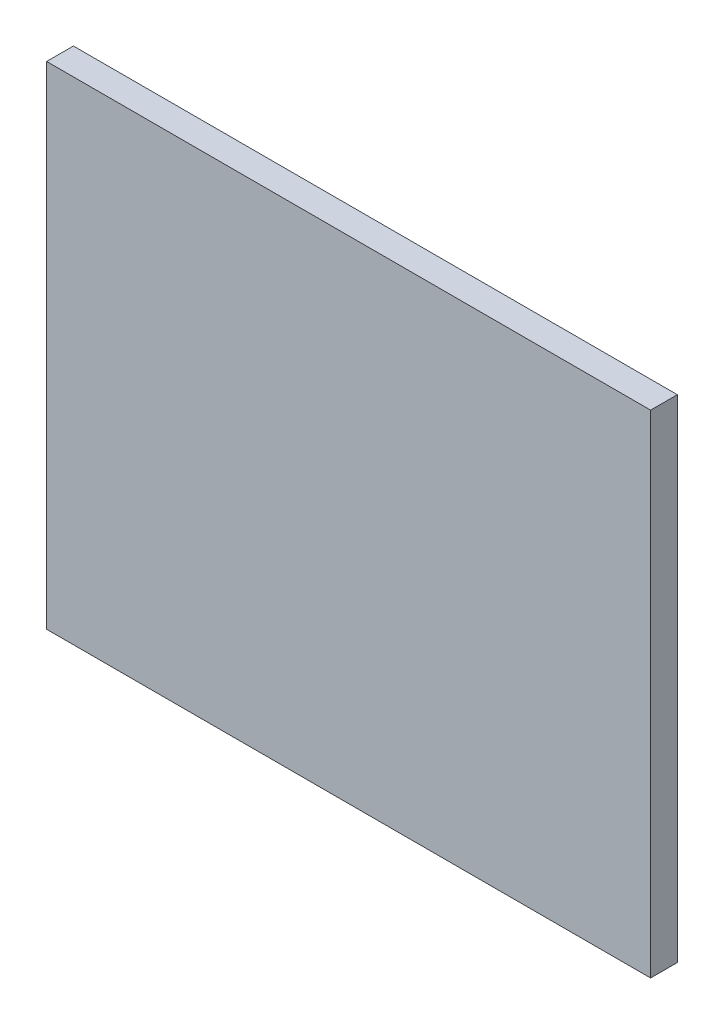
from build123d import *

# Parameters (mm, degrees)
SKETCH1_W           = 210
SKETCH1_H           = 171
BOSS_EXTRUDE1_DEPTH = 9.3


with BuildPart() as part:
    # Sketch1 → Boss-Extrude1 (new body)
    with BuildSketch(Plane.XY):
        Rectangle(SKETCH1_W, SKETCH1_H)
    extrude(amount=BOSS_EXTRUDE1_DEPTH)


solid = part.part
